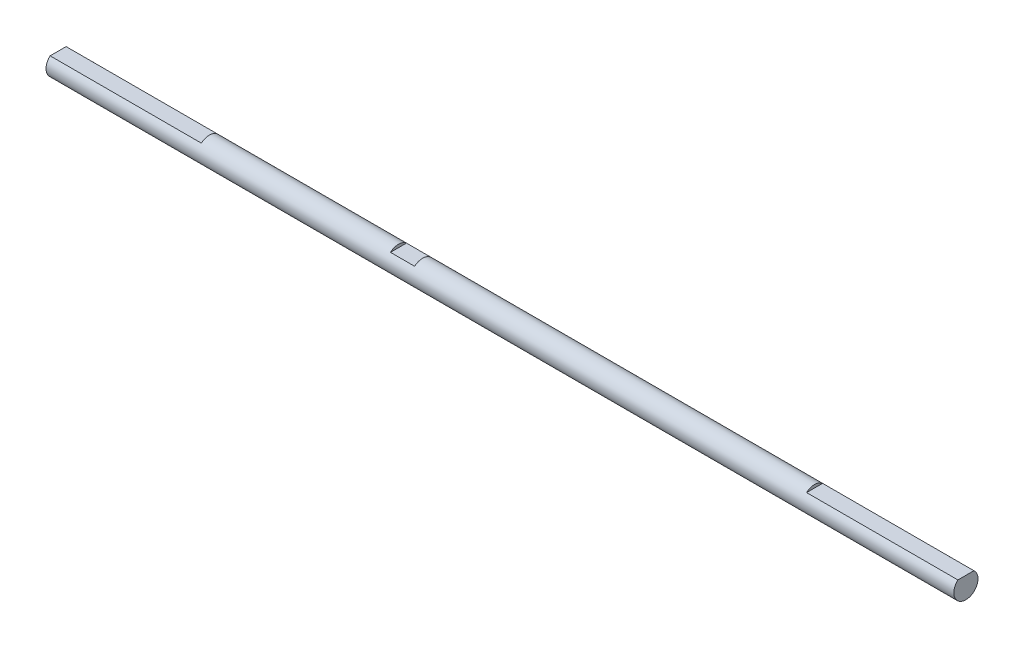
from build123d import *

# Parameters (mm, degrees)
BOSS_EXTRUDE1_DEPTH     = 75
SKETCH2_R               = 2
BOSS_EXTRUDE2_DEPTH     = 50
SKETCH3_W               = 4
SKETCH3_H               = 0.5
CUT_EXTRUDE1_DEPTH      = 3
CUT_EXTRUDE1_DEPTH_BACK = 3


with BuildPart() as part:
    # Sketch1 → Boss-Extrude1 (new body, symmetric)
    with BuildSketch(Plane(origin=(0, 0, 0), x_dir=(0, 0, -1), z_dir=(1, 0, 0))):
        with BuildLine():
            Line((-1.322875656, 1.5), (1.322875656, 1.5))
            ThreePointArc((1.322875656, 1.5), (0, -2), (-1.322875656, 1.5))
        make_face()
    extrude(amount=BOSS_EXTRUDE1_DEPTH, both=True)

    # Sketch2 → Boss-Extrude2 (add, symmetric)
    with BuildSketch(Plane(origin=(0, 0, 0), x_dir=(0, 0, -1), z_dir=(1, 0, 0))):
        Circle(SKETCH2_R)
    extrude(amount=BOSS_EXTRUDE2_DEPTH, both=True)

    # Sketch3 → Cut-Extrude1 (cut, two sides)
    with BuildSketch(Plane.XY) as cut_extrude1_sk:
        with Locations((-16.76, 1.75)):
            Rectangle(SKETCH3_W, SKETCH3_H)
    extrude(amount=CUT_EXTRUDE1_DEPTH, mode=Mode.SUBTRACT)
    extrude(cut_extrude1_sk.sketch, amount=-CUT_EXTRUDE1_DEPTH_BACK, mode=Mode.SUBTRACT)


solid = part.part
